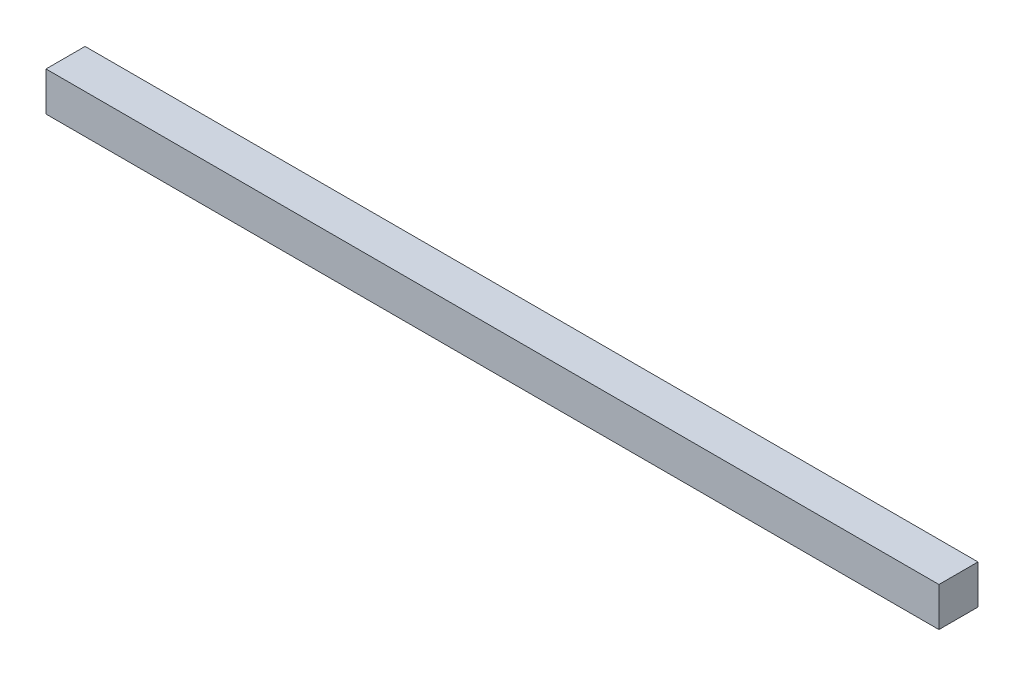
from build123d import *

# Parameters (mm, degrees)
SKETCH1_W           = 228.53
SKETCH1_H           = 10
BOSS_EXTRUDE1_DEPTH = 10


with BuildPart() as part:
    # Sketch1 → Boss-Extrude1 (new body)
    with BuildSketch(Plane(origin=(0, 0, 0), x_dir=(1, 0, 0), z_dir=(0, 1, 0))):
        Rectangle(SKETCH1_W, SKETCH1_H)
    extrude(amount=BOSS_EXTRUDE1_DEPTH)


solid = part.part
